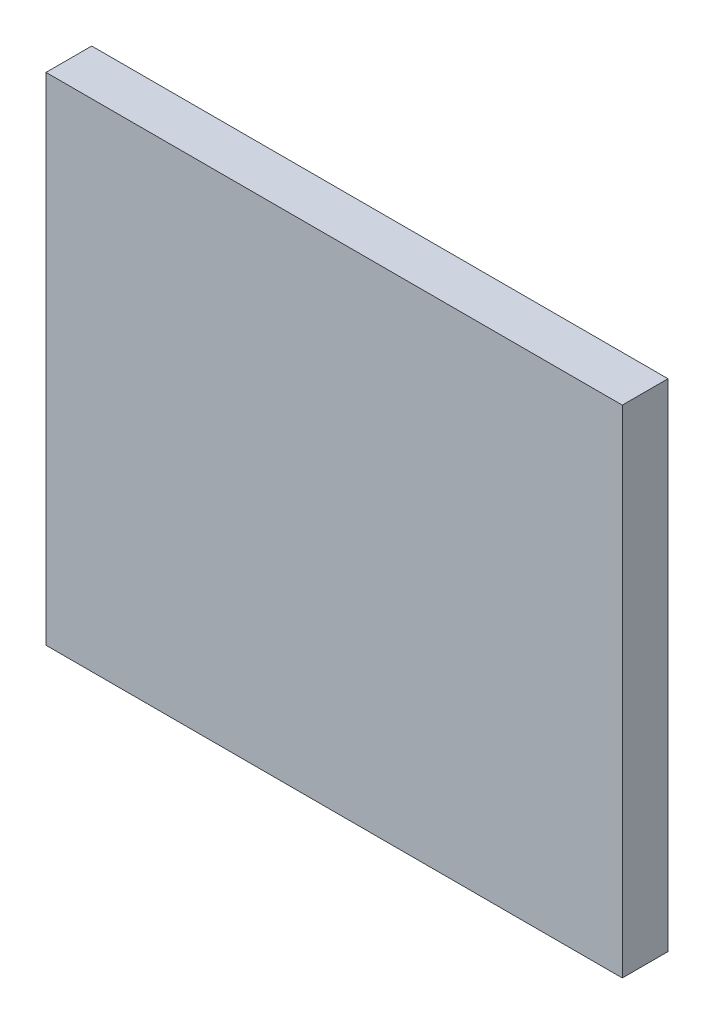
from build123d import *

# Parameters (mm, degrees)
SKETCH1_W           = 560.57
SKETCH1_H           = 482.6
BOSS_EXTRUDE1_DEPTH = 44.45
CUT_EXTRUDE1_DEPTH  = 152.4


with BuildPart() as part:
    # Sketch1 → Boss-Extrude1 (new body)
    with BuildSketch(Plane.XY):
        with Locations((280.285, -241.3)):
            Rectangle(SKETCH1_W, SKETCH1_H)
    extrude(amount=BOSS_EXTRUDE1_DEPTH)

    # Sketch2 → Cut-Extrude1 (cut, symmetric)
    with BuildSketch(Plane(origin=(0, -241.3, 0), x_dir=(-1, 0, 0), z_dir=(0, -1, 0))):
        with BuildLine():
            Line((-485.135, 0), (-485.135, -10))
            ThreePointArc((-485.135, -10), (-467.07, -23.003655986), (-449.005, -10))
            Line((-449.005, -10), (-449.005, 0))
            Line((-449.005, 0), (-485.135, 0))
        make_face()
        with BuildLine():
            Line((-391.635, -10), (-391.635, 0))
            Line((-391.635, 0), (-355.505, 0))
            Line((-355.505, 0), (-355.505, -10))
            ThreePointArc((-355.505, -10), (-373.57, -23.003655986), (-391.635, -10))
        make_face()
    cut_extrude1 = extrude(amount=CUT_EXTRUDE1_DEPTH, both=True, mode=Mode.SUBTRACT)

    # Mirror1: Cut-Extrude1 across plane
    add(cut_extrude1.mirror(Plane.ZY.offset(-280.285)), mode=Mode.SUBTRACT)


solid = part.part
